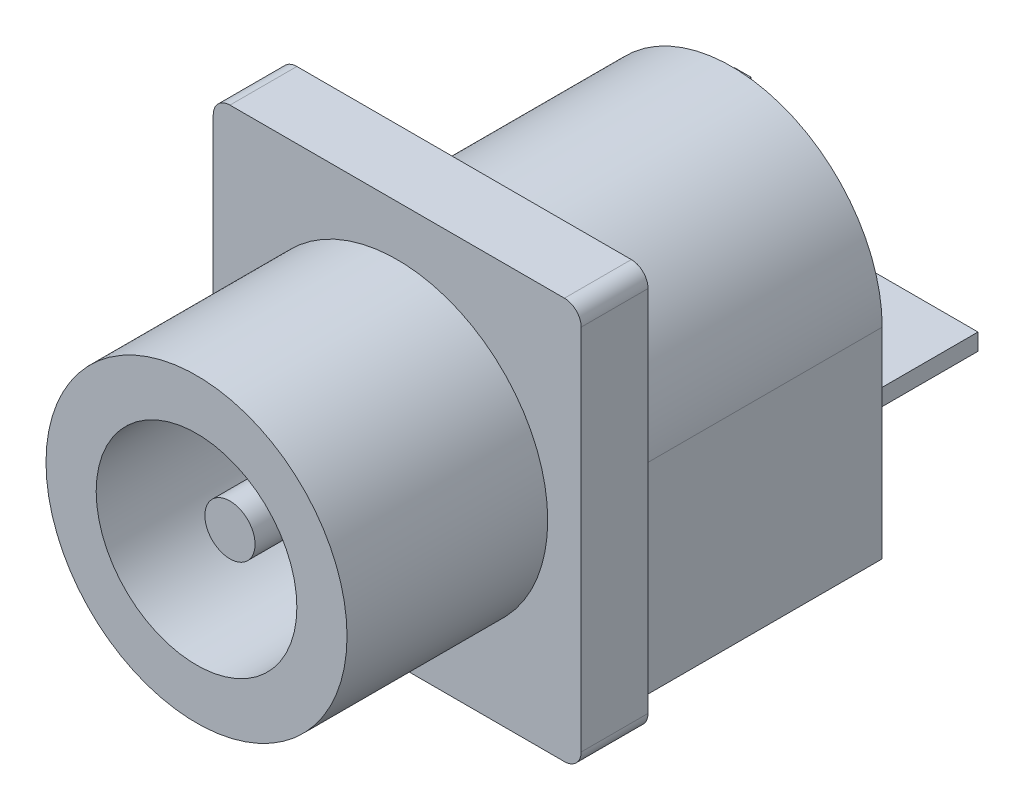
from build123d import *

# Parameters (mm, degrees)
SKETCH1_R           = 4.5
BOSS_EXTRUDE1_DEPTH = 6
SKETCH2_R           = 3
CUT_EXTRUDE1_DEPTH  = 5
SKETCH3_R           = 0.75
BOSS_EXTRUDE2_DEPTH = 4
BOSS_EXTRUDE3_DEPTH = 2
BOSS_EXTRUDE4_DEPTH = 8
SKETCH7_W           = 0.5
SKETCH7_H           = 3.5
SKETCH7_W_2         = 3.5
SKETCH7_H_2         = 0.5
BOSS_EXTRUDE5_DEPTH = 4
SKETCH8_W           = 6
SKETCH8_H           = 4
BOSS_EXTRUDE6_DEPTH = 1


with BuildPart() as part:
    # Sketch1 → Boss-Extrude1 (new body)
    with BuildSketch(Plane.XY):
        Circle(SKETCH1_R)
    extrude(amount=BOSS_EXTRUDE1_DEPTH)

    # Sketch2 → Cut-Extrude1 (cut)
    with BuildSketch(Plane.XY.offset(6)):
        Circle(SKETCH2_R)
    extrude(amount=-CUT_EXTRUDE1_DEPTH, mode=Mode.SUBTRACT)

    # Sketch3 → Boss-Extrude2 (add)
    with BuildSketch(Plane.XY.offset(1)):
        Circle(SKETCH3_R)
    extrude(amount=BOSS_EXTRUDE2_DEPTH)

    # Sketch5 → Boss-Extrude3 (add)
    with BuildSketch(Plane(origin=(0, 0, 0), x_dir=(-1, 0, 0), z_dir=(0, 0, -1))):
        with BuildLine():
            Line((-5, 6), (5, 6))
            ThreePointArc((5, 6), (5.353553391, 5.853553391), (5.5, 5.5))
            Line((5.5, 5.5), (5.5, -5.5))
            ThreePointArc((5.5, -5.5), (5.353553391, -5.853553391), (5, -6))
            Line((5, -6), (-5, -6))
            ThreePointArc((-5, -6), (-5.353553391, -5.853553391), (-5.5, -5.5))
            Line((-5.5, -5.5), (-5.5, 5.5))
            ThreePointArc((-5.5, 5.5), (-5.353553391, 5.853553391), (-5, 6))
        make_face()
    extrude(amount=BOSS_EXTRUDE3_DEPTH)

    # Sketch6 → Boss-Extrude4 (add)
    with BuildSketch(Plane(origin=(0, 0, -2), x_dir=(-1, 0, 0), z_dir=(0, 0, -1))):
        with BuildLine():
            Line((-4.5, 0), (-4.5, -6))
            Line((-4.5, -6), (4.5, -6))
            Line((4.5, -6), (4.5, 0))
            ThreePointArc((4.5, 0), (0, 4.5), (-4.5, 0))
        make_face()
    extrude(amount=BOSS_EXTRUDE4_DEPTH)

    # Sketch7 → Boss-Extrude5 (add)
    with BuildSketch(Plane(origin=(0, 0, -10), x_dir=(-1, 0, 0), z_dir=(0, 0, -1))):
        with Locations((3.672251412, -1.23876186)):
            Rectangle(SKETCH7_W, SKETCH7_H)
        with Locations((2.252036974, -5.358665001)):
            Rectangle(SKETCH7_W_2, SKETCH7_H_2)
        with Locations((-1.614241264, -2.943106028)):
            Rectangle(SKETCH7_W_2, SKETCH7_H_2)
    extrude(amount=BOSS_EXTRUDE5_DEPTH)

    # Sketch8 → Boss-Extrude6 (add)
    with BuildSketch(Plane(origin=(0, -6, 0), x_dir=(-1, 0, 0), z_dir=(0, -1, 0))):
        with Locations((-0.5, 8)):
            Rectangle(SKETCH8_W, SKETCH8_H)
    extrude(amount=BOSS_EXTRUDE6_DEPTH)


solid = part.part
